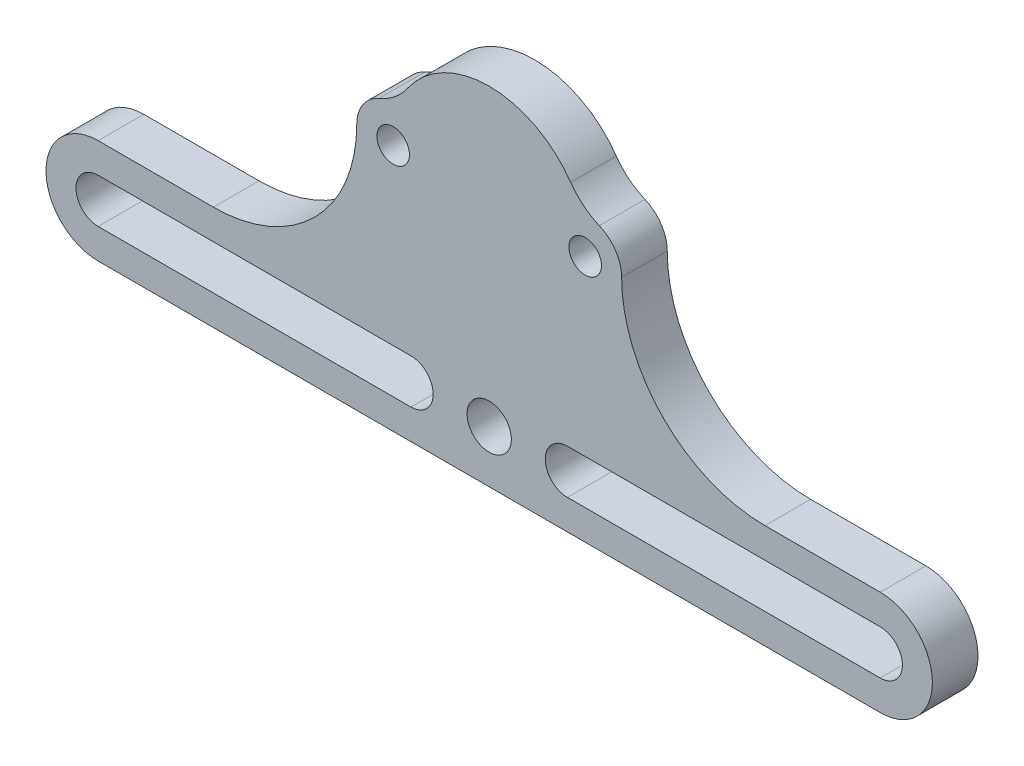
from build123d import *

# Parameters (mm, degrees)
SKETCH1_R           = 1.25
SKETCH1_R_2         = 1.7
BOSS_EXTRUDE1_DEPTH = 3.5


with BuildPart() as part:
    # Sketch1 → Boss-Extrude1 (new body)
    with BuildSketch(Plane.XY):
        with BuildLine():
            Line((-30, -19), (30, -19))
            ThreePointArc((30, -19), (34, -15), (30, -11))
            Line((30, -11), (21.16, -11))
            ThreePointArc((21.16, -11), (13.381825407, -7.778174593), (10.16, 0))
            ThreePointArc((10.16, 0), (9.693763482, 1.54530035), (8.450656284, 2.574870238))
            ThreePointArc((8.450656284, 2.574870238), (7.225912675, 3.308465338), (6.253653028, 4.35387))
            ThreePointArc((6.253653028, 4.35387), (0, 7.619997387), (-6.253653028, 4.353870001))
            ThreePointArc((-6.253653028, 4.353870001), (-7.225911419, 3.308463788), (-8.450654495, 2.574865992))
            ThreePointArc((-8.450654495, 2.574865992), (-9.693759643, 1.545297801), (-10.159995392, 0))
            ThreePointArc((-10.159995392, 0), (-13.381820799, -7.778174593), (-21.159995392, -11))
            Line((-21.159995392, -11), (-30, -11))
            ThreePointArc((-30, -11), (-34, -15), (-30, -19))
        make_face()
        with Locations((-7.366, 0)):
            Circle(SKETCH1_R, mode=Mode.SUBTRACT)
        with Locations((7.366, 0)):
            Circle(SKETCH1_R, mode=Mode.SUBTRACT)
        with Locations((0, -15)):
            Circle(SKETCH1_R_2, mode=Mode.SUBTRACT)
        with BuildLine():
            Line((-30, -13.3), (-6, -13.3))
            ThreePointArc((-6, -13.3), (-4.3, -15), (-6, -16.7))
            Line((-6, -16.7), (-30, -16.7))
            ThreePointArc((-30, -16.7), (-31.7, -15), (-30, -13.3))
        make_face(mode=Mode.SUBTRACT)
        with BuildLine():
            Line((30, -16.7), (6, -16.7))
            ThreePointArc((6, -16.7), (4.3, -15), (6, -13.3))
            Line((6, -13.3), (30, -13.3))
            ThreePointArc((30, -13.3), (31.7, -15), (30, -16.7))
        make_face(mode=Mode.SUBTRACT)
    extrude(amount=BOSS_EXTRUDE1_DEPTH)


solid = part.part
